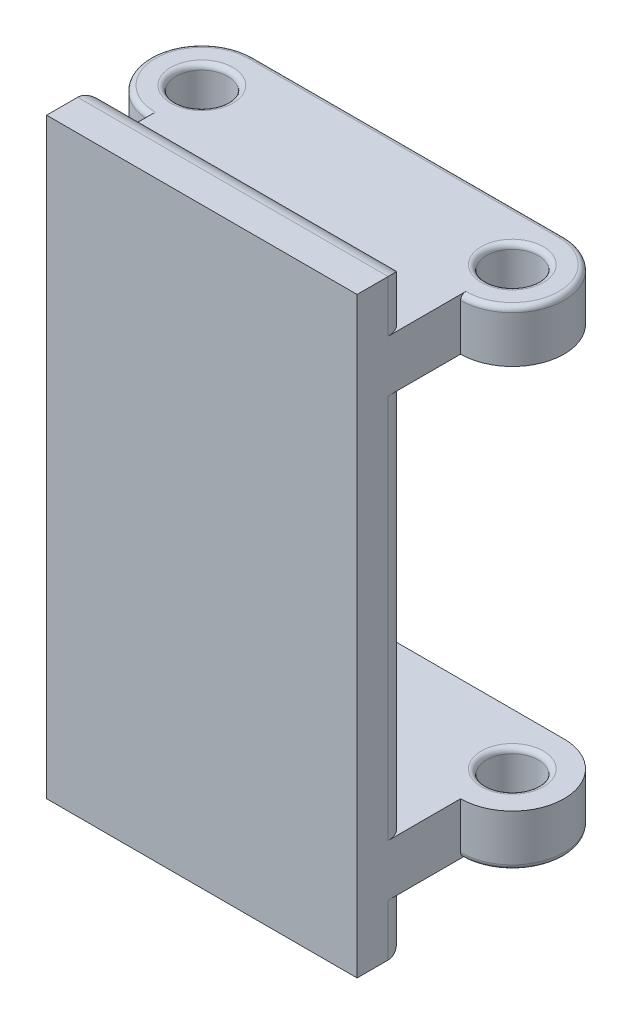
from build123d import *

# Parameters (mm, degrees)
SKETCH1_W           = 30
SKETCH1_H           = 57.2
BOSS_EXTRUDE2_DEPTH = 5
SKETCH3_R           = 2.5
BOSS_EXTRUDE3_DEPTH = 5
FILLET1_R           = 0.5
FILLET2_R           = 2


with BuildPart() as part:
    # Sketch1 → Boss-Extrude2 (new body)
    with BuildSketch(Plane.XY):
        with Locations((15, 28.6)):
            Rectangle(SKETCH1_W, SKETCH1_H)
    extrude(amount=BOSS_EXTRUDE2_DEPTH)

    # Sketch3 → Boss-Extrude3 (add)
    with BuildSketch(Plane(origin=(0, 10, 0), x_dir=(1, 0, 0), z_dir=(0, 1, 0))):
        with BuildLine():
            Line((30, 15), (0, 15))
            ThreePointArc((0, 15), (-5, 10), (0, 5))
            Line((0, 5), (0, 0))
            Line((0, 0), (30, 0))
            Line((30, 0), (30, 5))
            ThreePointArc((30, 5), (35, 10), (30, 15))
        make_face()
        with Locations((30, 10)):
            Circle(SKETCH3_R, mode=Mode.SUBTRACT)
        with Locations((0, 10)):
            Circle(SKETCH3_R, mode=Mode.SUBTRACT)
    boss_extrude3 = extrude(amount=-BOSS_EXTRUDE3_DEPTH)

    # Mirror1: Boss-Extrude3 across plane
    add(boss_extrude3.mirror(Plane.ZX.offset(28.6)))

    # Fillet1
    fillet1_edges = [part.edges().sort_by_distance(p)[0] for p in [
        (35, 5, -10),
        (-5, 5, -10),
        (15, 5, -15),
        (-2.5, 5, -10),
        (27.5, 5, -10),
        (27.5, 10, -10),
        (-2.5, 10, -10),
        (35, 52.2, -10),
        (15, 52.2, -15),
        (-5, 52.2, -10),
        (27.5, 47.2, -10),
        (-2.5, 47.2, -10),
        (27.5, 52.2, -10),
        (-2.5, 52.2, -10),
    ]]
    fillet(fillet1_edges, radius=FILLET1_R)

    # Fillet2
    fillet2_edges = [part.edges().sort_by_distance(p)[0] for p in [
        (0, 2.5, 0),
        (30, 28.6, 0),
        (0, 28.6, 0),
        (30, 54.7, 0),
        (15, 57.2, 0),
        (30, 2.5, 0),
        (15, 0, 0),
        (0, 54.7, 0),
    ]]
    fillet(fillet2_edges, radius=FILLET2_R)


solid = part.part
